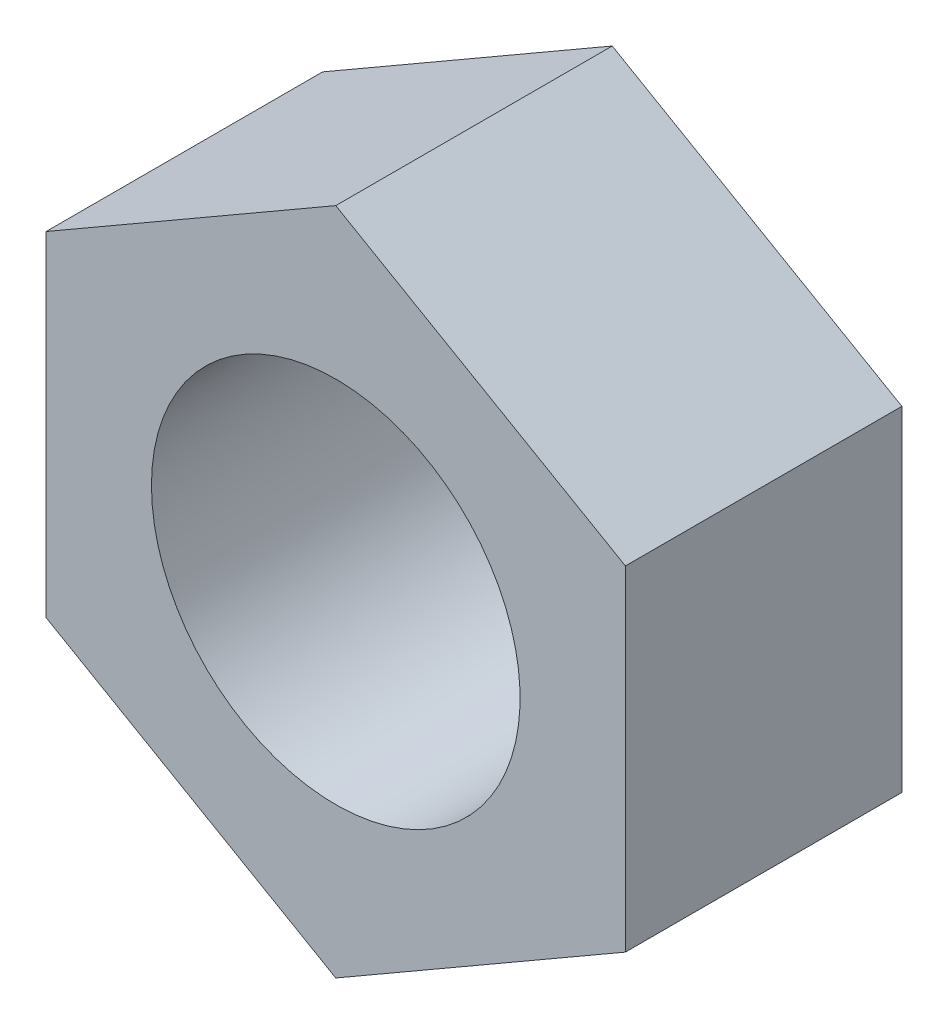
from build123d import *

# Parameters (mm, degrees)
EXTRUDE_1_DEPTH     = 10.5
SKETCH_2_R          = 7
CUT_EXTRUDE_1_DEPTH = 10.5


with BuildPart() as part:
    # 草图1 → 凸台-拉伸1 (new body)
    with BuildSketch(Plane.XY):
        Polygon((37.315481106, 15.159530396), (37.315481106, 2.457824474), (26.315481106, -3.893028487), (15.315481106, 2.457824474), (15.315481106, 15.159530396), (26.315481106, 21.510383357), align=None)
    extrude(amount=EXTRUDE_1_DEPTH)

    # 草图2 → 切除-拉伸1 (cut)
    with BuildSketch(Plane(origin=(0, 0, 0), x_dir=(-1, 0, 0), z_dir=(0, 0, -1))):
        with Locations((-26.315481106, 8.808677435)):
            Circle(SKETCH_2_R)
    extrude(amount=-CUT_EXTRUDE_1_DEPTH, mode=Mode.SUBTRACT)


solid = part.part
